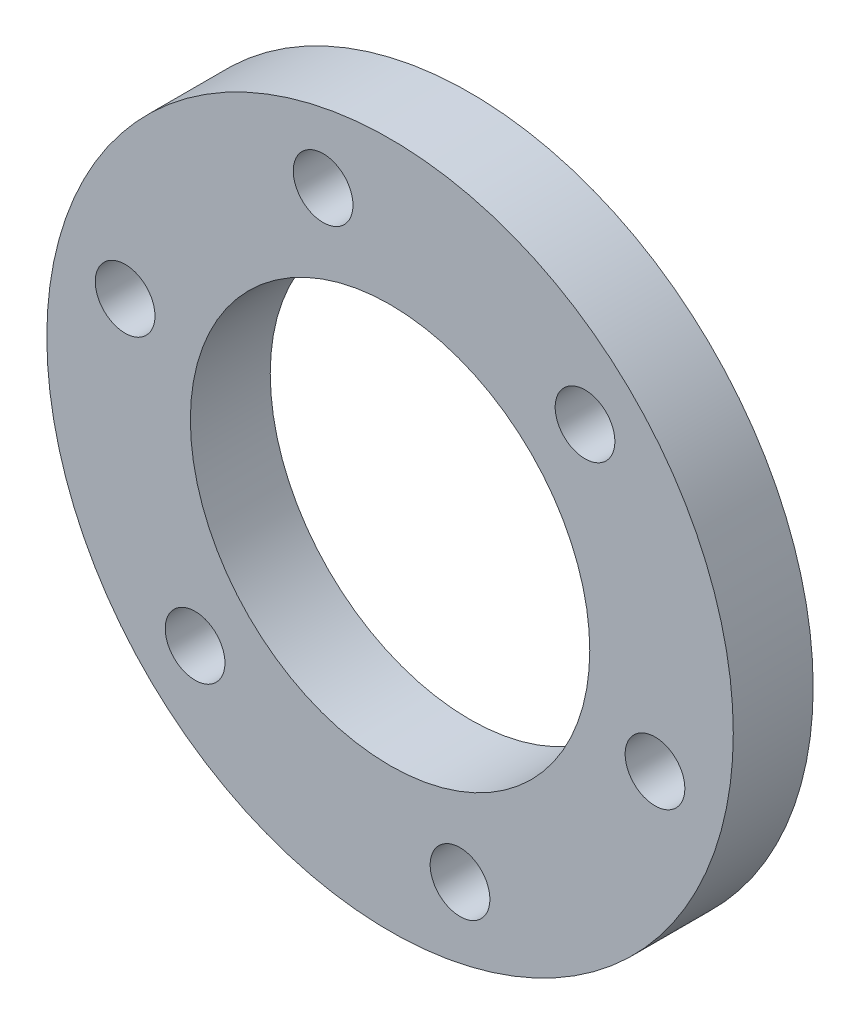
from build123d import *

# Parameters (mm, degrees)
SKETCH1_R             = 21.828125
SKETCH1_R_2           = 12.7
BOSS_EXTRUDE1_DEPTH   = 5.08
F_6_CLEARANCE_HOLE1_D = 3.7973


with BuildPart() as part:
    # Sketch1 → Boss-Extrude1 (new body)
    with BuildSketch(Plane.XY):
        Circle(SKETCH1_R)
        Circle(SKETCH1_R_2, mode=Mode.SUBTRACT)
    extrude(amount=BOSS_EXTRUDE1_DEPTH)

    # #6 Clearance Hole1 (through all)
    with Locations(Plane.XY.offset(5.08)):
        with Locations((-4.257431401, 16.98192349), (12.398693186, 12.296800947), (16.848688598, -4.589182799), (4.449995412, -16.885983746), (-12.398693186, -12.296800947), (-16.848688598, 4.589182799)):
            Hole(F_6_CLEARANCE_HOLE1_D / 2)


solid = part.part
